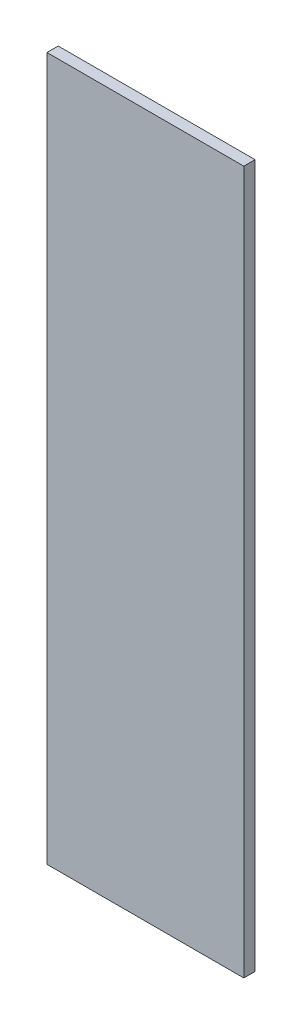
from build123d import *

# Parameters (mm, degrees)
SKETCH1_W           = 28
SKETCH1_H           = 100
BOSS_EXTRUDE1_DEPTH = 1.6


with BuildPart() as part:
    # Sketch1 → Boss-Extrude1 (new body)
    with BuildSketch(Plane.XY):
        with Locations((0, 50)):
            Rectangle(SKETCH1_W, SKETCH1_H)
    extrude(amount=BOSS_EXTRUDE1_DEPTH)


solid = part.part
